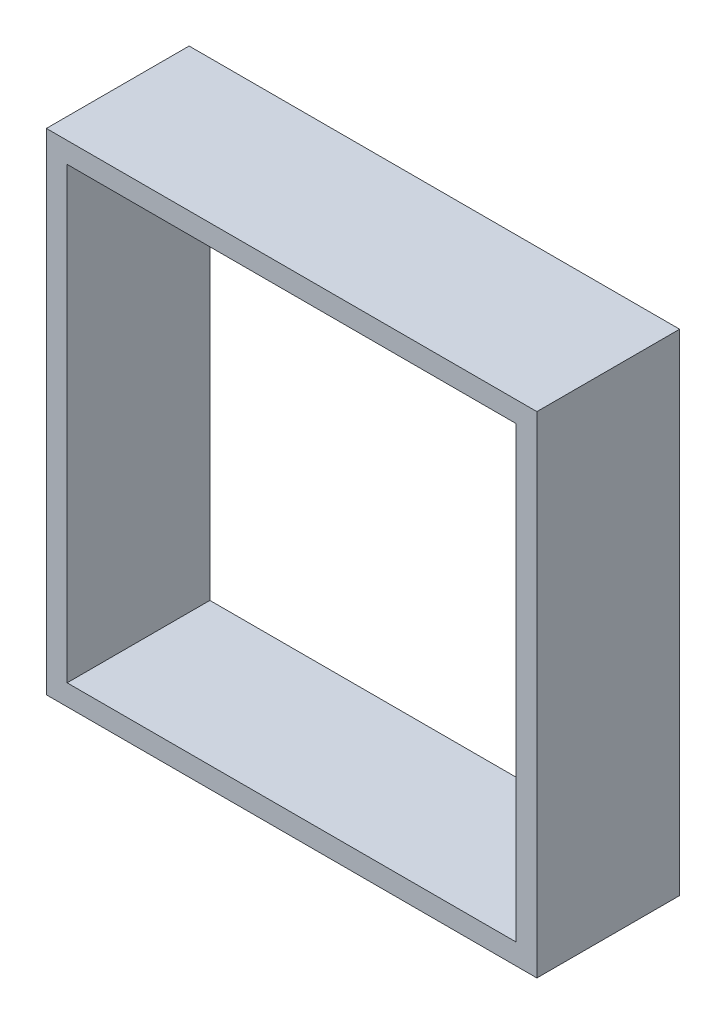
from build123d import *

# Parameters (mm, degrees)
SKETCH1_W           = 18.9
SKETCH1_H           = 18.9
SKETCH1_W_2         = 17.3
SKETCH1_H_2         = 17.3
BOSS_EXTRUDE1_DEPTH = 5.5


with BuildPart() as part:
    # Sketch1 → Boss-Extrude1 (new body)
    with BuildSketch(Plane.XY):
        Rectangle(SKETCH1_W, SKETCH1_H)
        Rectangle(SKETCH1_W_2, SKETCH1_H_2, mode=Mode.SUBTRACT)
    extrude(amount=BOSS_EXTRUDE1_DEPTH)


solid = part.part
